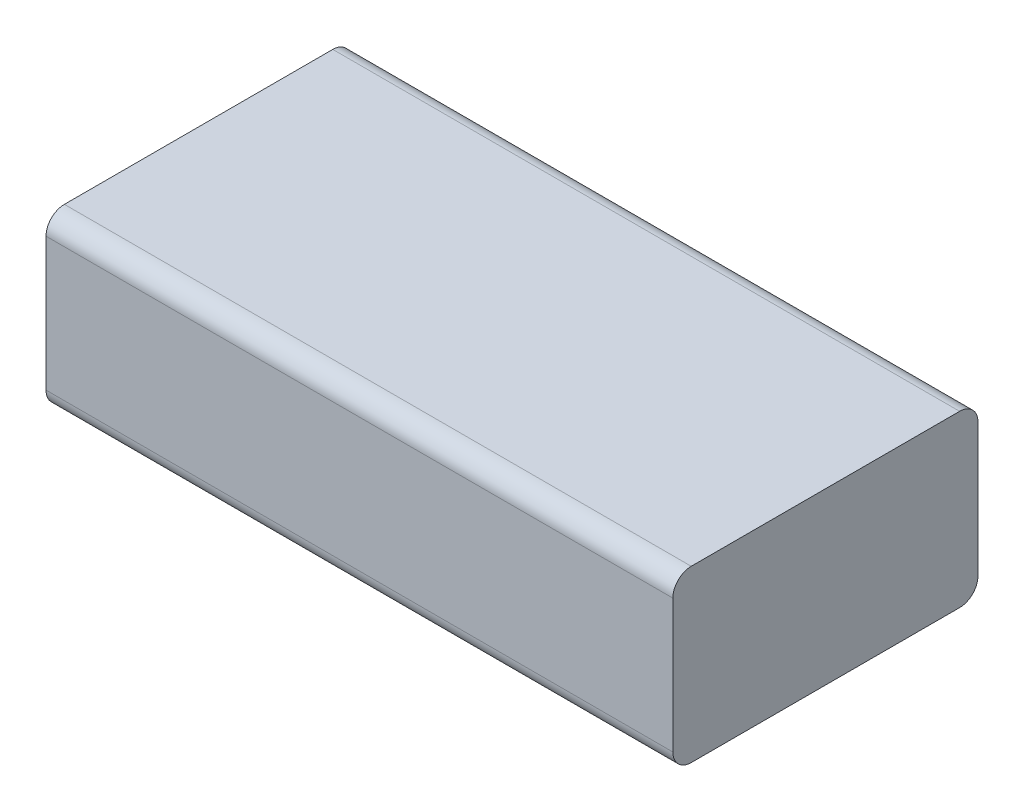
from build123d import *

# Parameters (mm, degrees)
SKETCH1_W           = 68.2
SKETCH1_H           = 33.2
BOSS_EXTRUDE1_DEPTH = 18.5
FILLET1_R           = 2


with BuildPart() as part:
    # Sketch1 → Boss-Extrude1 (new body)
    with BuildSketch(Plane(origin=(0, 0, 0), x_dir=(1, 0, 0), z_dir=(0, 1, 0))):
        Rectangle(SKETCH1_W, SKETCH1_H)
    extrude(amount=BOSS_EXTRUDE1_DEPTH)

    # Fillet1
    fillet1_edges = [part.edges().sort_by_distance(p)[0] for p in [
        (0, 18.5, 16.6),
        (0, 0, 16.6),
        (0, 0, -16.6),
        (0, 18.5, -16.6),
    ]]
    fillet(fillet1_edges, radius=FILLET1_R)


solid = part.part
